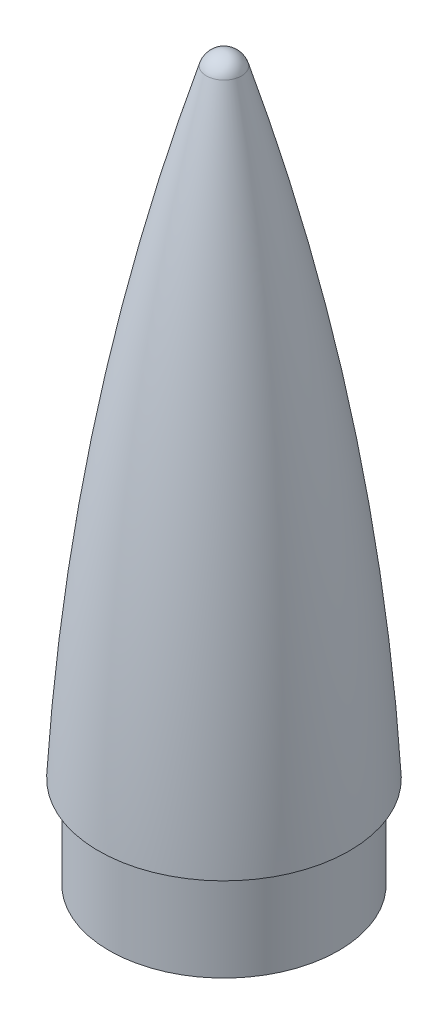
from build123d import *

# Parameters (mm, degrees)
CUT_EXTRUDE2_DEPTH = 40


with BuildPart() as part:
    # Sketch1 → Revolve2 (revolve)
    with BuildSketch(Plane.XY):
        with BuildLine():
            Line((-20.5, 0), (-18.75, 0))
            Line((-18.75, 0), (-18.75, -15))
            Line((-18.75, -15), (-17.25, -15))
            Line((-17.25, -15), (-17.25, -0.84156))
            ThreePointArc((-17.25, -0.84156), (-11.642902, 49.610871), (0, 99.02069))
            Line((0, 99.02069), (0, 103.02069))
            ThreePointArc((0, 103.02069), (-1.787656, 102.429898), (-2.871224, 100.890213))
            ThreePointArc((-2.871224, 100.890213), (-14.743163, 50.979359), (-20.5, 0))
        make_face()
    revolve(axis=Axis((0, -1000, 0), (0, 1, 0)))

    # Sketch2 → Cut-Extrude2 (cut)
    with BuildSketch(Plane.XZ.offset(15)):
        with BuildLine():
            ThreePointArc((-16.084459, -6.233191), (-5.907565, -8.625), (0, 0))
            ThreePointArc((0, 0), (-5.907565, 8.625), (-16.084459, 6.233191))
            ThreePointArc((-16.084459, 6.233191), (-17.25, 0), (-16.084459, -6.233191))
        make_face()
        with BuildLine():
            ThreePointArc((16.084459, 6.233191), (5.907565, 8.625), (0, 0))
            ThreePointArc((0, 0), (5.907565, -8.625), (16.084459, -6.233191))
            ThreePointArc((16.084459, -6.233191), (16.956111, -3.170613), (17.25, 0))
            ThreePointArc((17.25, 0), (16.956111, 3.170613), (16.084459, 6.233191))
        make_face()
    extrude(amount=-CUT_EXTRUDE2_DEPTH, mode=Mode.SUBTRACT)


solid = part.part
